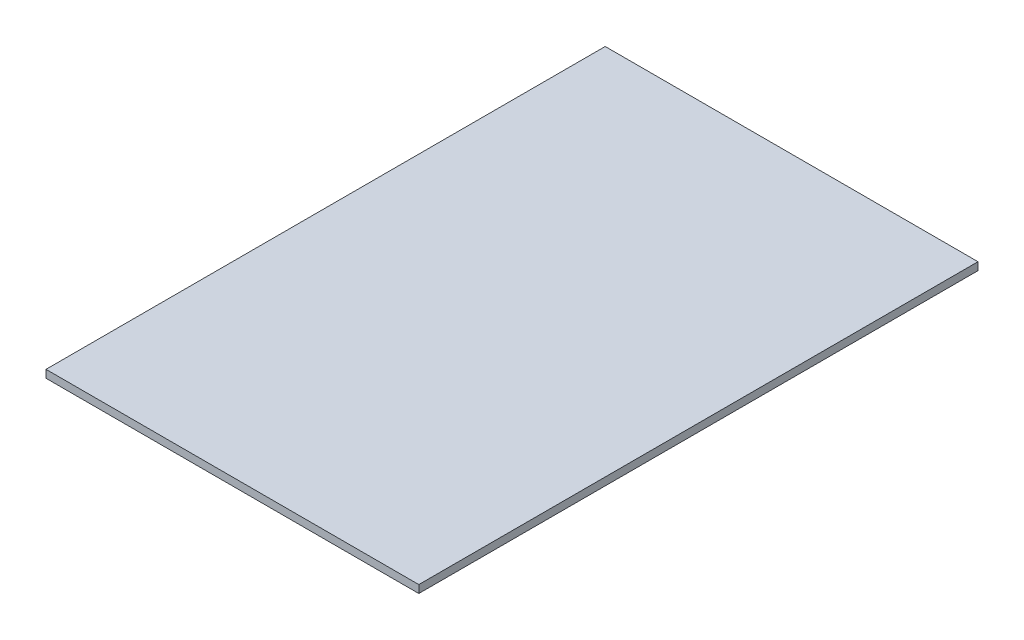
from build123d import *

# Parameters (mm, degrees)
SKETCH1_W           = 609.6
SKETCH1_H           = 914.4
BOSS_EXTRUDE1_DEPTH = 6.35


with BuildPart() as part:
    # Sketch1 → Boss-Extrude1 (new body, symmetric)
    with BuildSketch(Plane(origin=(0, 0, 0), x_dir=(1, 0, 0), z_dir=(0, 1, 0))):
        Rectangle(SKETCH1_W, SKETCH1_H)
    extrude(amount=BOSS_EXTRUDE1_DEPTH, both=True)


solid = part.part
